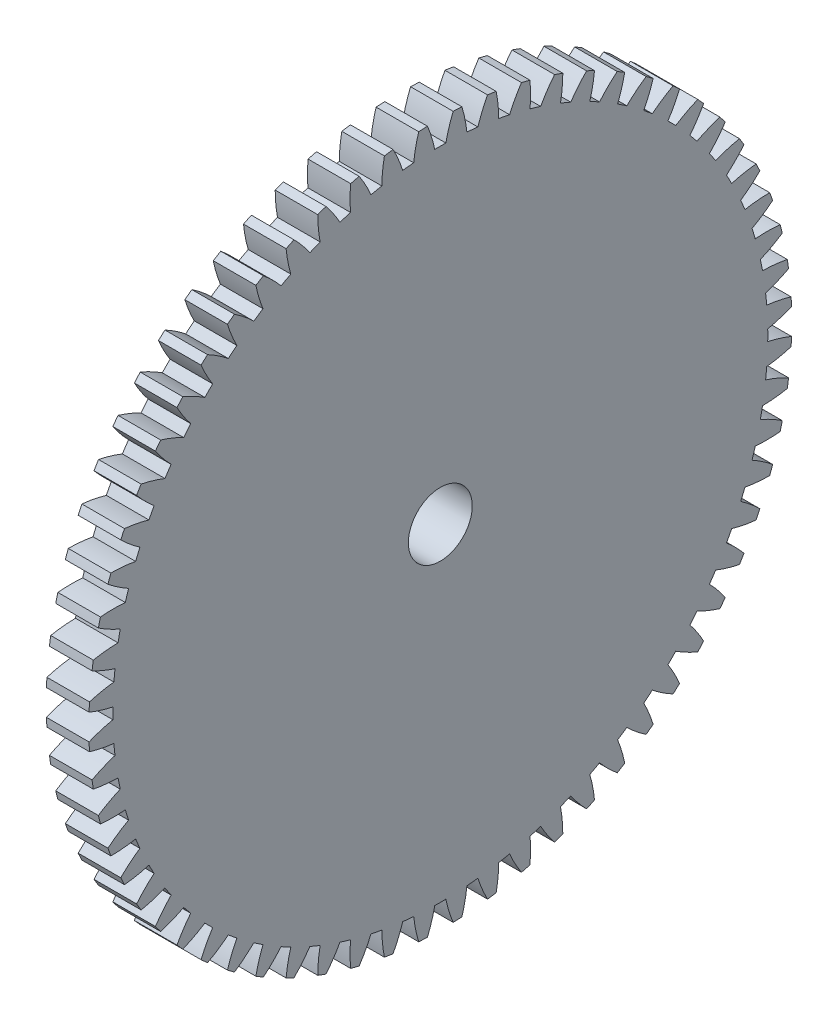
from build123d import *

# Parameters (mm, degrees)
BASPROSKE_W      = 6.35
BASPROSKE_H      = 52.3875
TOOTHCUT_DEPTH   = 75.358744022
TEETHCUTS_COUNT  = 64
TEETHCUTS_ANGLE  = 354.375
HUBNEAONESKE_R   = 6.35
HUBNEARONE_DEPTH = 6.3500508
BORSKE_R         = 4.7625
BORE_DEPTH       = 12.7000508


with BuildPart() as part:
    # BasProSke → Base-Revolve (revolve)
    with BuildSketch(Plane(origin=(0, 0, 0), x_dir=(1, 0, 0), z_dir=(0, 1, 0)), mode=Mode.PRIVATE) as base_revolve_sk:
        with Locations((3.175, 26.19375)):
            Rectangle(BASPROSKE_W, BASPROSKE_H)
    revolve(base_revolve_sk.sketch.rotate(Axis((-10, 0, 0), (1, 0, 0)), 180), axis=Axis((-10, 0, 0), (1, 0, 0)))

    # TooCutSke → ToothCut (cut, through all)
    with BuildSketch(Plane(origin=(0, 0, 0), x_dir=(0, 0, -1), z_dir=(1, 0, 0))):
        with BuildLine():
            ThreePointArc((0.824920189, 48.807384285), (0, 48.814355), (-0.824920189, 48.807384285))
            ThreePointArc((-0.824920189, 48.807384285), (-1.295085054, 50.61782597), (-1.929736013, 52.377363482))
            ThreePointArc((-1.929736013, 52.377363482), (0, 52.4129), (1.929736013, 52.377363482))
            ThreePointArc((1.929736013, 52.377363482), (1.295085054, 50.61782597), (0.824920189, 48.807384285))
        make_face()
    toothcut = extrude(amount=TOOTHCUT_DEPTH, mode=Mode.SUBTRACT)

    # TeethCuts: ToothCut ×64 about axis
    teethcuts_axis = Axis((-10, 0, 0), (1, 0, 0))
    for i in range(1, TEETHCUTS_COUNT):
        add(toothcut.rotate(teethcuts_axis, i * TEETHCUTS_ANGLE / (TEETHCUTS_COUNT - 1)), mode=Mode.SUBTRACT)

    # HubNeaOneSke → HubNearOne (add)
    with BuildSketch(Plane.ZY):
        with Locations(Location((0, 0, 0), (0, 0, 180))):
            Circle(HUBNEAONESKE_R)
    extrude(amount=HUBNEARONE_DEPTH)

    # BorSke → Bore (cut, symmetric)
    with BuildSketch(Plane(origin=(0, 0, 0), x_dir=(0, 0, -1), z_dir=(1, 0, 0))):
        with Locations(Location((0, 0, 0), (0, 0, 180))):
            Circle(BORSKE_R)
    extrude(amount=BORE_DEPTH, both=True, mode=Mode.SUBTRACT)


solid = part.part
